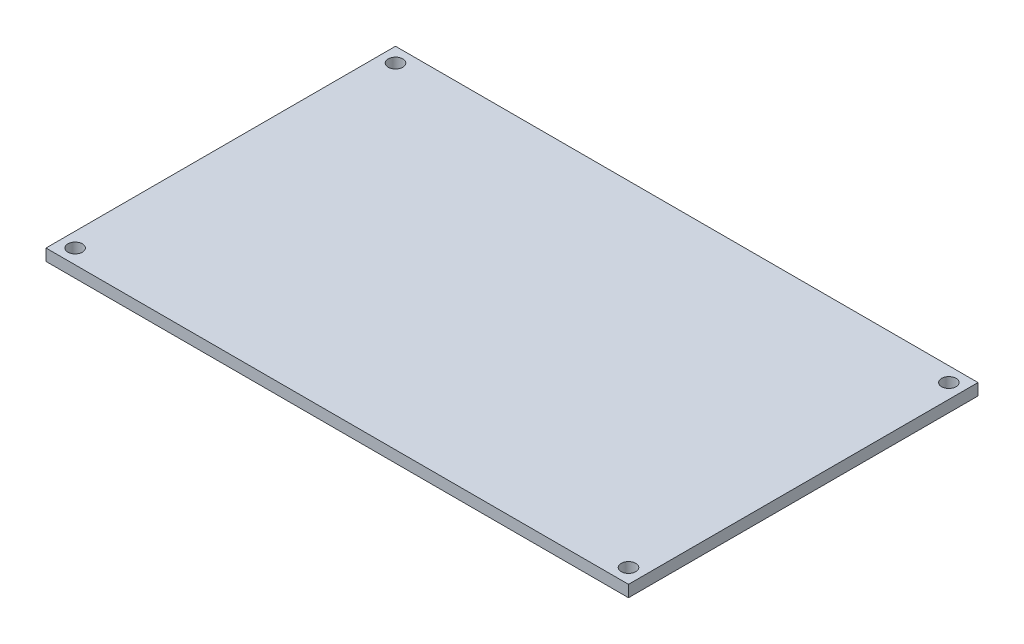
from build123d import *

# Parameters (mm, degrees)
SKETCH2_W                 = 200
SKETCH2_H                 = 120
BOSS_EXTRUDE1_DEPTH       = 4
F_3_0MM_DOWEL_HOLE1_D     = 5
F_3_0MM_DOWEL_HOLE1_DEPTH = 20
F_3_0MM_DOWEL_HOLE1_TIP   = 1.502151548


with BuildPart() as part:
    # Sketch2 → Boss-Extrude1 (new body)
    with BuildSketch(Plane(origin=(0, 0, 0), x_dir=(1, 0, 0), z_dir=(0, 1, 0))):
        Rectangle(SKETCH2_W, SKETCH2_H)
    extrude(amount=BOSS_EXTRUDE1_DEPTH)

    # Ø3.0mm Dowel Hole1
    with Locations(Plane(origin=(-95, 4, -55), x_dir=(0, 0, 1), z_dir=(0, 1, 0))):
        with Locations((0, 0), (110, 0), (110, 190), (0, 190)):
            Hole(F_3_0MM_DOWEL_HOLE1_D / 2, depth=F_3_0MM_DOWEL_HOLE1_DEPTH)
            with Locations((0, 0, -(F_3_0MM_DOWEL_HOLE1_DEPTH + F_3_0MM_DOWEL_HOLE1_TIP / 2))):  # 118° drill point
                Cone(0, F_3_0MM_DOWEL_HOLE1_D / 2, F_3_0MM_DOWEL_HOLE1_TIP, mode=Mode.SUBTRACT)


solid = part.part
